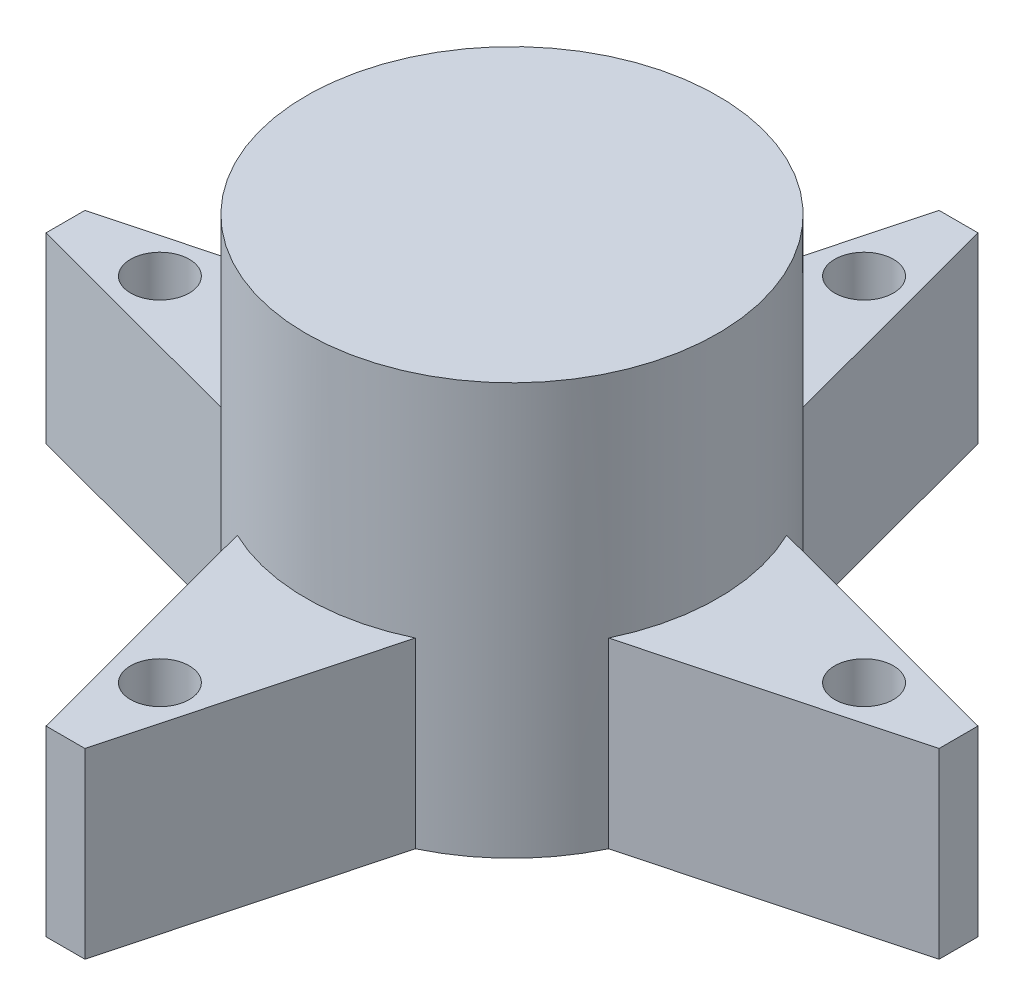
from build123d import *

# Parameters (mm, degrees)
SKETCH1_R           = 7.895
BOSS_EXTRUDE1_DEPTH = 15.79
SKETCH2_R           = 1.125
BOSS_EXTRUDE2_DEPTH = 7


with BuildPart() as part:
    # Sketch1 → Boss-Extrude1 (new body)
    with BuildSketch(Plane(origin=(0, 0, 0), x_dir=(1, 0, 0), z_dir=(0, 1, 0))):
        Circle(SKETCH1_R)
    extrude(amount=BOSS_EXTRUDE1_DEPTH)

    # Sketch2 → Boss-Extrude2 (add)
    with BuildSketch(Plane(origin=(0, 0, 0), x_dir=(1, 0, 0), z_dir=(0, 1, 0))):
        Polygon((7.118925688, -3.413491182), (17.121835898, -0.746202613), (17.121835898, 0.746202613), (7.118925688, 3.413491182), (3.413491182, 7.118925688), (0.746202613, 17.121835898), (-0.746202613, 17.121835898), (-3.413491182, 7.118925688), (-7.118925688, 3.413491182), (-17.121835898, 0.746202613), (-17.121835898, -0.746202613), (-7.118925688, -3.413491182), (-3.413491182, -7.118925688), (-0.746202613, -17.121835898), (0.746202613, -17.121835898), (3.413491182, -7.118925688), align=None)
        with Locations((13.5, 0)):
            Circle(SKETCH2_R, mode=Mode.SUBTRACT)
        with Locations((0, -13.5)):
            Circle(SKETCH2_R, mode=Mode.SUBTRACT)
        with Locations((-13.5, 0)):
            Circle(SKETCH2_R, mode=Mode.SUBTRACT)
        with Locations((0, 13.5)):
            Circle(SKETCH2_R, mode=Mode.SUBTRACT)
    extrude(amount=BOSS_EXTRUDE2_DEPTH)


solid = part.part
